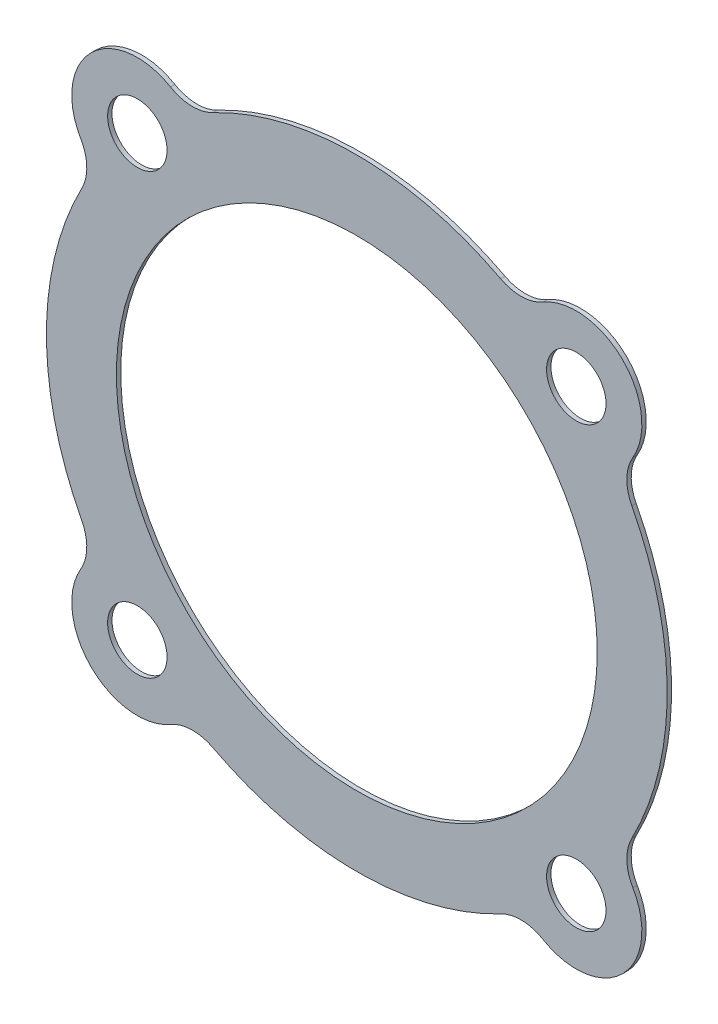
from build123d import *

# Parameters (mm, degrees)
SKETCH1_R           = 34.925
SKETCH1_R_2         = 4.318
BOSS_EXTRUDE1_DEPTH = 0.635


with BuildPart() as part:
    # Sketch1 → Boss-Extrude1 (new body)
    with BuildSketch(Plane.XY):
        with BuildLine():
            ThreePointArc((20.903132924, 39.946417348), (0, 45.085), (-20.903132924, 39.946417348))
            ThreePointArc((-20.903132924, 39.946417348), (-24.001012396, 39.224535565), (-27.060305383, 40.09556768))
            ThreePointArc((-27.060305383, 40.09556768), (-38.615101321, 38.615101321), (-40.09556768, 27.060305383))
            ThreePointArc((-40.09556768, 27.060305383), (-39.224535565, 24.001012396), (-39.946417348, 20.903132924))
            ThreePointArc((-39.946417348, 20.903132924), (-45.085, 0), (-39.946417348, -20.903132924))
            ThreePointArc((-39.946417348, -20.903132924), (-39.224535565, -24.001012396), (-40.09556768, -27.060305383))
            ThreePointArc((-40.09556768, -27.060305383), (-38.615101321, -38.615101321), (-27.060305383, -40.09556768))
            ThreePointArc((-27.060305383, -40.09556768), (-24.001012396, -39.224535565), (-20.903132924, -39.946417348))
            ThreePointArc((-20.903132924, -39.946417348), (0, -45.085), (20.903132924, -39.946417348))
            ThreePointArc((20.903132924, -39.946417348), (24.001012396, -39.224535565), (27.060305383, -40.09556768))
            ThreePointArc((27.060305383, -40.09556768), (38.615101321, -38.615101321), (40.09556768, -27.060305383))
            ThreePointArc((40.09556768, -27.060305383), (39.224535565, -24.001012396), (39.946417348, -20.903132924))
            ThreePointArc((39.946417348, -20.903132924), (45.085, 0), (39.946417348, 20.903132924))
            ThreePointArc((39.946417348, 20.903132924), (39.224535565, 24.001012396), (40.09556768, 27.060305383))
            ThreePointArc((40.09556768, 27.060305383), (38.615101321, 38.615101321), (27.060305383, 40.09556768))
            ThreePointArc((27.060305383, 40.09556768), (24.001012396, 39.224535565), (20.903132924, 39.946417348))
        make_face()
        Circle(SKETCH1_R, mode=Mode.SUBTRACT)
        with Locations((31.87990923, 31.87990923)):
            Circle(SKETCH1_R_2, mode=Mode.SUBTRACT)
        with Locations((31.87990923, -31.87990923)):
            Circle(SKETCH1_R_2, mode=Mode.SUBTRACT)
        with Locations((-31.87990923, -31.87990923)):
            Circle(SKETCH1_R_2, mode=Mode.SUBTRACT)
        with Locations((-31.87990923, 31.87990923)):
            Circle(SKETCH1_R_2, mode=Mode.SUBTRACT)
    extrude(amount=BOSS_EXTRUDE1_DEPTH)


solid = part.part
